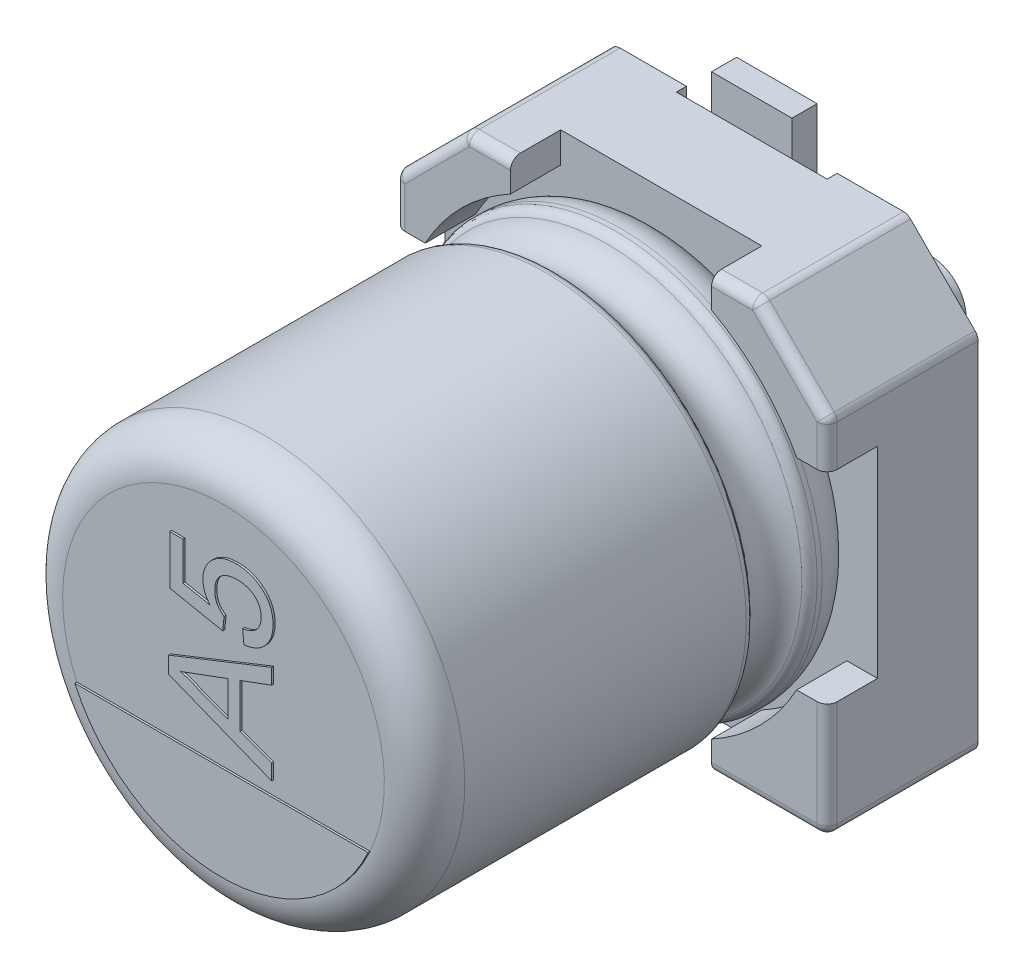
from build123d import *

# Parameters (mm, degrees)
BOSS_EXTRUDE1_DEPTH  = 1
BOSS_EXTRUDE2_DEPTH  = 0.5
SKETCH7_R            = 0.35
SPACER_PAD_DEPTH     = 0.15
SKETCH9_W            = 1.5
SKETCH9_H            = 1.75
CUT_EXTRUDE1_DEPTH   = 0.1
FILLET1_R            = 0.1
FILLET2_R            = 0.1
CATHODE_MARKER_DEPTH = 0.02
TEXT_2_DEPTH         = 0.02
SKETCH19_W           = 0.8
SKETCH19_H           = 2
BOSS_EXTRUDE6_DEPTH  = 0.25


with BuildPart() as part:
    # Sketch2 → Boss-Extrude1 (new body)
    with BuildSketch(Plane.XY):
        Polygon((-2.15, 1.45), (-1.45, 2.15), (1.45, 2.15), (2.15, 1.45), (2.15, -2.15), (-2.15, -2.15), align=None)
    extrude(amount=BOSS_EXTRUDE1_DEPTH)

    # Sketch4 → Boss-Extrude2 (add)
    with BuildSketch(Plane.XY.offset(1)):
        with BuildLine():
            Line((-2.15, 1.45), (-1.45, 2.15))
            Line((-1.45, 2.15), (-1, 2.15))
            Line((-1, 2.15), (-1, 1.846618531))
            ThreePointArc((-1, 1.846618531), (-1.48492424, 1.48492424), (-1.846618531, 1))
            Line((-1.846618531, 1), (-2.15, 1))
            Line((-2.15, 1), (-2.15, 1.45))
        make_face()
        with BuildLine():
            Line((1.45, 2.15), (2.15, 1.45))
            Line((2.15, 1.45), (2.15, 1))
            Line((2.15, 1), (1.846618531, 1))
            ThreePointArc((1.846618531, 1), (1.48492424, 1.48492424), (1, 1.846618531))
            Line((1, 1.846618531), (1, 2.15))
            Line((1, 2.15), (1.45, 2.15))
        make_face()
        with BuildLine():
            Line((2.15, -1), (2.15, -2.15))
            Line((2.15, -2.15), (1, -2.15))
            Line((1, -2.15), (1, -1.846618531))
            ThreePointArc((1, -1.846618531), (1.48492424, -1.48492424), (1.846618531, -1))
            Line((1.846618531, -1), (2.15, -1))
        make_face()
        with BuildLine():
            Line((-2.15, -1), (-2.15, -2.15))
            Line((-2.15, -2.15), (-1, -2.15))
            Line((-1, -2.15), (-1, -1.846618531))
            ThreePointArc((-1, -1.846618531), (-1.48492424, -1.48492424), (-1.846618531, -1))
            Line((-1.846618531, -1), (-2.15, -1))
        make_face()
    extrude(amount=BOSS_EXTRUDE2_DEPTH)

    # Sketch7 → Spacer pad (add)
    with BuildSketch(Plane(origin=(0, 0, 0), x_dir=(1, 0, 0), z_dir=(0, 0, -1))):
        with Locations((-1.531222847, 1.404412223)):
            Circle(SKETCH7_R)
        with Locations((1.531222847, 1.404412223)):
            Circle(SKETCH7_R)
        with Locations((-1.531222847, -1.404412223)):
            Circle(SKETCH7_R)
        with Locations((1.531222847, -1.404412223)):
            Circle(SKETCH7_R)
    extrude(amount=SPACER_PAD_DEPTH)

    # Sketch9 → Cut-Extrude1 (cut)
    with BuildSketch(Plane(origin=(0, 0, 0), x_dir=(1, 0, 0), z_dir=(0, 0, -1))):
        with Locations((0, 1.275)):
            Rectangle(SKETCH9_W, SKETCH9_H)
        with Locations((0, -1.275)):
            Rectangle(SKETCH9_W, SKETCH9_H)
    extrude(amount=-CUT_EXTRUDE1_DEPTH, mode=Mode.SUBTRACT)

    # Fillet1
    fillet1_edges = [part.edges().sort_by_distance(p)[0] for p in [
        (2.15, -2.15, 0.75),
        (-2.15, -2.15, 0.75),
        (-2.15, 1.45, 0.75),
        (-1.45, 2.15, 0.75),
        (1.45, 2.15, 0.75),
        (2.15, 1.45, 0.75),
    ]]
    fillet(fillet1_edges, radius=FILLET1_R)

    # Sketch10 → Revolve1 (revolve)
    with BuildSketch(Plane(origin=(0, 0, 0), x_dir=(0, 0, -1), z_dir=(1, 0, 0))):
        with BuildLine():
            Line((-5.353626625, 0), (-1, 0))
            Line((-1, 0), (-1, 1.6))
            ThreePointArc((-1, 1.6), (-1.117157288, 1.882842712), (-1.4, 2))
            Line((-1.4, 2), (-1.449422929, 2))
            ThreePointArc((-1.449422929, 2), (-1.504479696, 1.983479053), (-1.541344666, 1.939375046))
            ThreePointArc((-1.541344666, 1.939375046), (-1.801990181, 1.767472047), (-2.062635697, 1.939375046))
            ThreePointArc((-2.062635697, 1.939375046), (-2.099500666, 1.983479053), (-2.154557434, 2))
            Line((-2.154557434, 2), (-4.953626625, 2))
            ThreePointArc((-4.953626625, 2), (-5.236469337, 1.882842712), (-5.353626625, 1.6))
            Line((-5.353626625, 1.6), (-5.353626625, 0))
        make_face()
    revolve(axis=Axis((0, 0, -18.9630778), (0, 0, 1)))

    # Fillet2
    fillet2_edges = [part.edges().sort_by_distance(p)[0] for p in [
        (1.525, -2.15, 1.5),
        (2.120710678, -2.120710678, 1.5),
        (2.15, 1.204289322, 1.5),
        (2.142387953, 1.446846987, 1.5),
        (1.204289322, 2.15, 1.5),
        (1.446846987, 2.142387953, 1.5),
        (-1.204289322, 2.15, 1.5),
        (-1.446846987, 2.142387953, 1.5),
        (-1.8, 1.8, 1.5),
        (-2.142387953, 1.446846987, 1.5),
        (-2.15, -1.525, 1.5),
        (-2.120710678, -2.120710678, 1.5),
        (2.15, -1.525, 1.5),
        (1.8, 1.8, 1.5),
        (-2.15, 1.204289322, 1.5),
        (-1.525, -2.15, 1.5),
    ]]
    fillet(fillet2_edges, radius=FILLET2_R)

    # Sketch13 → Cathode marker (add)
    with BuildSketch(Plane.XY.offset(5.353626625)):
        with BuildLine():
            Line((-1.458175323, -0.658577808), (1.458175323, -0.658577808))
            ThreePointArc((1.458175323, -0.658577808), (0, -1.6), (-1.458175323, -0.658577808))
        make_face()
    extrude(amount=CATHODE_MARKER_DEPTH)

    # Sketch15 → Text 2 (add)
    with BuildSketch(Plane.XY.offset(5.353626625)):
        Polygon((0.5, -0.52202004), (-0.527327474, -0.114134813), (-0.527327474, 0.049266232), (0.5, 0.457151459), (0.5, 0.303422768), (0.183899239, 0.186531341), (0.183899239, -0.251399922), (0.5, -0.368291349), align=None)
        with BuildLine():
            Line((0.065361453, -0.207771432), (0.065361453, 0.14290285))
            Line((0.065361453, 0.14290285), (-0.20464128, 0.043092389))
            add(Edge.make_bspline(
                [(-0.20464128, 0.043092389), (-0.215073818, 0.039266012), (-0.235471399, 0.031784723), (-0.265107362, 0.020627867), (-0.293250889, 0.010435143), (-0.319498442, 0.000440341), (-0.344231293, -0.008582146), (-0.367282383, -0.016898404), (-0.388491496, -0.025123112), (-0.402194768, -0.030058875), (-0.408789689, -0.032434291)],
                knots=[0, 0, 0, 0, 1.225184869, 2.395467751, 3.491410812, 4.525364584, 5.492066482, 6.394148129, 7.227157926, 8, 8, 8, 8], degree=3))
            add(Edge.make_bspline(
                [(-0.408789689, -0.032434291), (-0.392530569, -0.036373337), (-0.359882051, -0.044282991), (-0.312080343, -0.060634454), (-0.264822924, -0.079646404), (-0.234382757, -0.094916958), (-0.219046914, -0.102610306)],
                knots=[0, 0, 0, 0, 0.989154277, 1.986234384, 2.985459177, 4, 4, 4, 4], degree=3))
            Line((-0.219046914, -0.102610306), (0.065361453, -0.207771432))
        make_face(mode=Mode.SUBTRACT)
        with BuildLine():
            Line((0.223411834, 0.514156609), (0.210240969, 0.645865259))
            add(Edge.make_bspline(
                [(0.210240969, 0.645865259), (0.217662028, 0.647169382), (0.232097144, 0.649706103), (0.252992401, 0.654540105), (0.272404679, 0.660818097), (0.290502099, 0.667872113), (0.307093304, 0.676257001), (0.32244026, 0.685342097), (0.335998198, 0.69605611), (0.348476211, 0.707320457), (0.359471547, 0.719683938), (0.368740995, 0.733265852), (0.376828026, 0.747687255), (0.383449329, 0.763123793), (0.388295773, 0.779599126), (0.392128479, 0.796903565), (0.394059761, 0.815259938), (0.39443953, 0.827784366), (0.39463308, 0.834167471)],
                knots=[0, 0, 0, 0, 1.237781394, 2.407677316, 3.51963579, 4.58689595, 5.594855907, 6.570874, 7.510833816, 8.428091223, 9.330271693, 10.221190844, 11.124215526, 12.043132878, 12.973586933, 13.941700858, 14.950982896, 16, 16, 16, 16], degree=3))
            add(Edge.make_bspline(
                [(0.39463308, 0.834167471), (0.3944417, 0.841997269), (0.39406745, 0.857308782), (0.390968307, 0.879598259), (0.385705739, 0.900576895), (0.378874887, 0.920443812), (0.369522636, 0.938881595), (0.357976474, 0.955835609), (0.344878756, 0.971904176), (0.329303341, 0.986153158), (0.312336747, 0.999119589), (0.293819768, 1.010311681), (0.274009016, 1.019733552), (0.252909186, 1.027665817), (0.230399493, 1.033523196), (0.206599755, 1.037831777), (0.181494791, 1.040597713), (0.164287513, 1.040858185), (0.155499561, 1.040991211)],
                knots=[0, 0, 0, 0, 1.052750423, 2.05869932, 3.018624241, 3.958205853, 4.878289862, 5.789216265, 6.712947111, 7.659433357, 8.620775926, 9.5811884, 10.56329027, 11.567503128, 12.60809625, 13.686605721, 14.818523251, 16, 16, 16, 16], degree=3))
            add(Edge.make_bspline(
                [(0.155499561, 1.040991211), (0.147124757, 1.040840016), (0.130817071, 1.040545603), (0.107070368, 1.038066171), (0.084741282, 1.033883078), (0.063583705, 1.028470546), (0.043928252, 1.021010055), (0.025489938, 1.012161491), (0.008660077, 1.001321629), (-0.00708535, 0.989261567), (-0.021200492, 0.975487454), (-0.033118941, 0.959813203), (-0.043549991, 0.942853707), (-0.052008922, 0.924267383), (-0.058293589, 0.904043288), (-0.063129076, 0.882382392), (-0.065672343, 0.859059932), (-0.066118205, 0.843021915), (-0.066347197, 0.834784855)],
                knots=[0, 0, 0, 0, 1.165854935, 2.270189951, 3.319242023, 4.32700288, 5.306253956, 6.24172124, 7.169108591, 8.088047231, 8.999810445, 9.905349262, 10.822648491, 11.767237767, 12.739852311, 13.766490849, 14.852878837, 16, 16, 16, 16], degree=3))
            add(Edge.make_bspline(
                [(-0.066347197, 0.834784855), (-0.066045926, 0.824543261), (-0.065468157, 0.804902202), (-0.06065641, 0.776667361), (-0.052780332, 0.75103943), (-0.041429729, 0.728065303), (-0.027498802, 0.707608453), (-0.011552276, 0.689318488), (0.005980659, 0.672681258), (0.019200253, 0.663602271), (0.025848858, 0.659036124)],
                knots=[0, 0, 0, 0, 1.182633468, 2.268023356, 3.298275715, 4.269491976, 5.216938987, 6.149685646, 7.069410919, 8, 8, 8, 8], degree=3))
            Line((0.025848858, 0.659036124), (0.012677993, 0.527327474))
            Line((0.012677993, 0.527327474), (-0.514156609, 0.632694394))
            Line((-0.514156609, 0.632694394), (-0.514156609, 1.120016401))
            Line((-0.514156609, 1.120016401), (-0.382447958, 1.120016401))
            Line((-0.382447958, 1.120016401), (-0.382447958, 0.740325057))
            Line((-0.382447958, 0.740325057), (-0.116355325, 0.688053187))
            add(Edge.make_bspline(
                [(-0.116355325, 0.688053187), (-0.121808832, 0.695320517), (-0.132518657, 0.709592405), (-0.14654176, 0.731853992), (-0.158362302, 0.754433896), (-0.168042331, 0.777200674), (-0.175583057, 0.800335172), (-0.180822005, 0.823697786), (-0.184362794, 0.847368062), (-0.184710424, 0.863240379), (-0.184884983, 0.871210529)],
                knots=[0, 0, 0, 0, 1.093835215, 2.148119334, 3.164235237, 4.159999629, 5.123971815, 6.089888814, 7.040853737, 8, 8, 8, 8], degree=3))
            add(Edge.make_bspline(
                [(-0.184884983, 0.871210529), (-0.184613122, 0.881583081), (-0.184077764, 0.902009153), (-0.179681854, 0.932108666), (-0.172212562, 0.960885034), (-0.162176354, 0.988582053), (-0.148800156, 1.014734586), (-0.132935744, 1.039899019), (-0.113809934, 1.063567488), (-0.092160153, 1.085880971), (-0.068094439, 1.106194961), (-0.042286485, 1.124175874), (-0.014506429, 1.139042992), (0.014653573, 1.151473324), (0.04567042, 1.160861532), (0.078117966, 1.167983909), (0.112397978, 1.171792794), (0.135734837, 1.172392773), (0.14767936, 1.172699861)],
                knots=[0, 0, 0, 0, 0.99184379, 1.95318097, 2.901668786, 3.831684196, 4.764819115, 5.705879134, 6.672196848, 7.669818607, 8.675456628, 9.680130933, 10.672473775, 11.683959944, 12.707147321, 13.767588937, 14.857383263, 16, 16, 16, 16], degree=3))
            add(Edge.make_bspline(
                [(0.14767936, 1.172699861), (0.159076386, 1.172466659), (0.181588765, 1.172006016), (0.214764917, 1.168230959), (0.246732751, 1.162012449), (0.277586934, 1.15368758), (0.307152236, 1.142439564), (0.335524158, 1.128796774), (0.36299875, 1.113059051), (0.37993525, 1.100438214), (0.388459237, 1.094086261)],
                knots=[0, 0, 0, 0, 1.059692978, 2.093196008, 3.100373587, 4.086253034, 5.061402885, 6.037282833, 7.012182238, 8, 8, 8, 8], degree=3))
            add(Edge.make_bspline(
                [(0.388459237, 1.094086261), (0.398407566, 1.086015313), (0.417976997, 1.070138892), (0.44340804, 1.042666196), (0.464920924, 1.013039556), (0.482819959, 0.981432427), (0.49653916, 0.947449511), (0.506016391, 0.911269897), (0.512286706, 0.873005478), (0.51287209, 0.846746591), (0.513170865, 0.833344292)],
                knots=[0, 0, 0, 0, 1.023063757, 2.01247625, 2.982117532, 3.944599247, 4.908953799, 5.902627458, 6.929519989, 8, 8, 8, 8], degree=3))
            add(Edge.make_bspline(
                [(0.513170865, 0.833344292), (0.512946009, 0.822289055), (0.512506147, 0.800662793), (0.5087007, 0.768993541), (0.502588826, 0.738889583), (0.493966122, 0.710236332), (0.482550414, 0.683293865), (0.468955441, 0.657678748), (0.452590601, 0.633860572), (0.434142295, 0.611584538), (0.413454647, 0.591478154), (0.391279735, 0.573229999), (0.367205206, 0.557550437), (0.341567374, 0.544132603), (0.31436974, 0.532964232), (0.285444606, 0.524416174), (0.255070847, 0.517646483), (0.234075489, 0.515332098), (0.223411834, 0.514156609)],
                knots=[0, 0, 0, 0, 1.108915132, 2.169260591, 3.195158146, 4.188014069, 5.165918008, 6.126692062, 7.092678666, 8.060306793, 9.02401023, 9.982884032, 10.937400194, 11.901029891, 12.882656982, 13.882099599, 14.924306988, 16, 16, 16, 16], degree=3))
        make_face()
    extrude(amount=TEXT_2_DEPTH)

    # Sketch19 → Boss-Extrude6 (add)
    with BuildSketch(Plane(origin=(0, 0, 0.1), x_dir=(1, 0, 0), z_dir=(0, 0, -1))):
        with Locations((0, 1.5)):
            Rectangle(SKETCH19_W, SKETCH19_H)
        with Locations((0, -1.5)):
            Rectangle(SKETCH19_W, SKETCH19_H)
    extrude(amount=BOSS_EXTRUDE6_DEPTH)


solid = part.part
